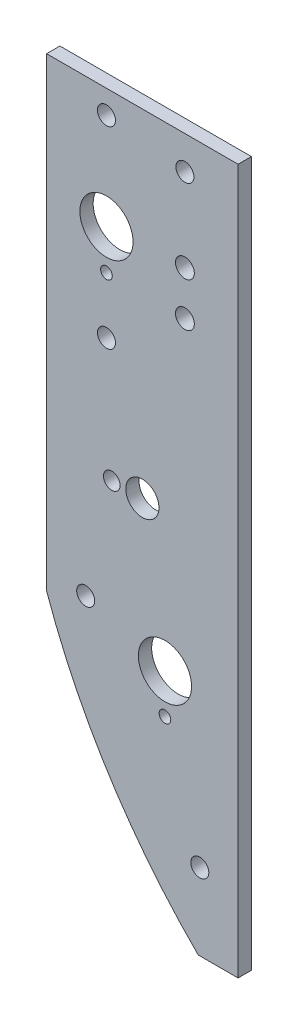
from build123d import *

# Parameters (mm, degrees)
BOSS_EXTRUDE1_DEPTH             = 3.175
F_1_2_0_5_DIAMETER_HOLE1_D      = 12.7
F_5_16_0_3125_DIAMETER_HOLE1_D  = 7.9375
F_5_32_0_15625_DIAMETER_HOLE1_D = 3.96875
F_7_64_0_10938_DIAMETER_HOLE1_D = 2.778252
F_6_CLEARANCE_HOLE1_D           = 4.3053
F_16_0_177_DIAMETER_HOLE1_D     = 4.4958


with BuildPart() as part:
    # Sketch1 → Boss-Extrude1 (new body)
    with BuildSketch(Plane.XY):
        with BuildLine():
            Line((-45.72, 26.9875), (-45.72, -84.1375))
            ThreePointArc((-45.72, -84.1375), (-30.833523511, -114.746148224), (-9.525, -141.2875))
            Line((-9.525, -141.2875), (0, -141.2875))
            Line((0, -141.2875), (0, 26.9875))
            Line((0, 26.9875), (-45.72, 26.9875))
        make_face()
    extrude(amount=-BOSS_EXTRUDE1_DEPTH)

    # 1/2 (0.5) Diameter Hole1 (through all)
    with Locations(Plane.XY):
        with Locations((-17.4625, -86.5505), (-31.4325, -1.620345612)):
            Hole(F_1_2_0_5_DIAMETER_HOLE1_D / 2)

    # 5/16 (0.3125) Diameter Hole1 (through all)
    with Locations(Plane.XY):
        with Locations((-22.86, -53.5305)):
            Hole(F_5_16_0_3125_DIAMETER_HOLE1_D / 2)

    # 5/32 (0.15625) Diameter Hole1 (through all)
    with Locations(Plane.XY):
        with Locations((-30.161117219, -53.5305)):
            Hole(F_5_32_0_15625_DIAMETER_HOLE1_D / 2)

    # 7/64 (0.10938) Diameter Hole1 (through all)
    with Locations(Plane.XY):
        with Locations((-17.464635625, -95.966719242), (-31.4325, -11.158858051)):
            Hole(F_7_64_0_10938_DIAMETER_HOLE1_D / 2)

    # #6 Clearance Hole1 (through all)
    with Locations(Plane(origin=(0, 0, -3.175), x_dir=(-1, 0, 0), z_dir=(0, 0, -1))):
        with Locations((12.7, 19.05), (36.3855, -80.4545), (9.144, -122.9995), (31.4325, -24.620045612), (31.4325, 21.404754388)):
            Hole(F_6_CLEARANCE_HOLE1_D / 2)

    # #16 (0.177) Diameter Hole1 (through all)
    with Locations(Plane(origin=(0, 0, -3.175), x_dir=(-1, 0, 0), z_dir=(0, 0, -1))):
        with Locations((12.7, -0.780389216), (12.7, -11.284610784)):
            Hole(F_16_0_177_DIAMETER_HOLE1_D / 2)


solid = part.part
